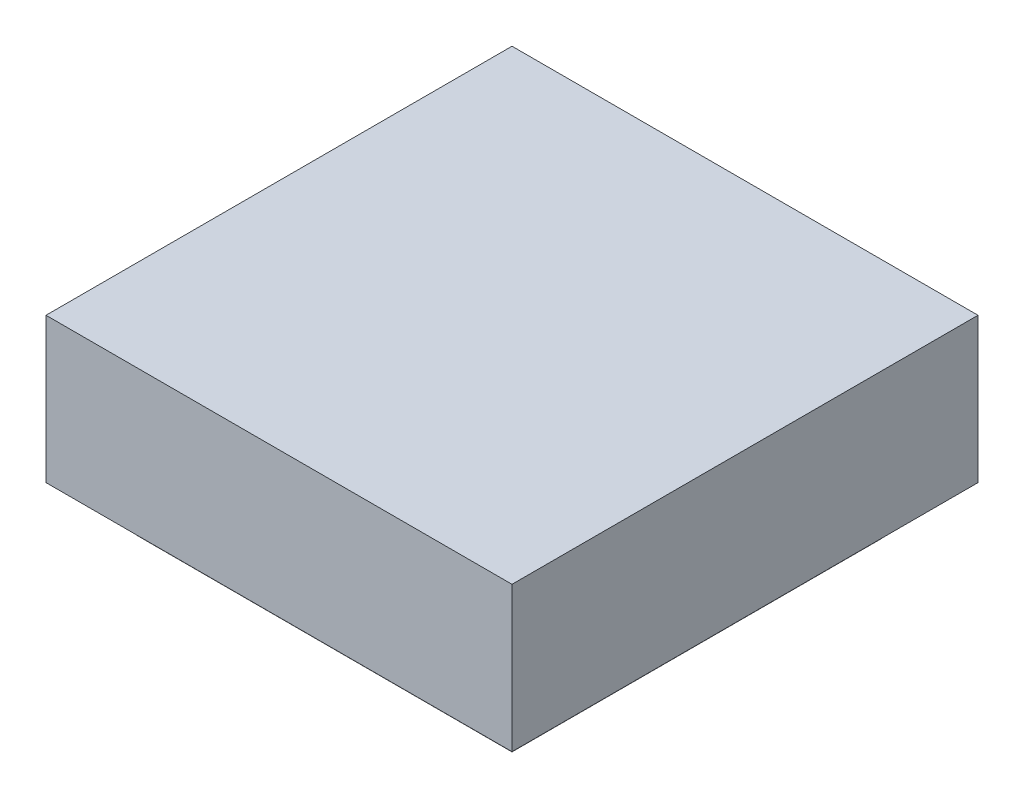
from build123d import *

# Parameters (mm, degrees)
SALIENTE_EXTRUIR1_DEPTH = 32
CORTAR_EXTRUIR2_DEPTH   = 33
SALIENTE_EXTRUIR2_DEPTH = 0.01
SALIENTE_EXTRUIR3_DEPTH = 0.01
SALIENTE_EXTRUIR5_DEPTH = 0.01
SALIENTE_EXTRUIR6_DEPTH = 0.01


with BuildPart() as part:
    # Croquis1 → Saliente-Extruir1 (new body)
    with BuildSketch(Plane.XY):
        Polygon((-23.483096056, 8.186360271), (-55.483096056, 8.189793686), (-55.483096056, 18.141275036), (-23.483096056, 18.141275036), align=None)
        Polygon((-23.483096056, 8.186360271), (-35.959662641, -4.290206314), (-43.003096056, -4.290206314), (-55.483096056, 8.189793686), align=None)
    extrude(amount=SALIENTE_EXTRUIR1_DEPTH)

    # Croquis2 → Cortar-Extruir2 (cut)
    with BuildSketch(Plane(origin=(-23.483096056, 0, 0), x_dir=(0, 0, -1), z_dir=(1, 0, 0))):
        Polygon((-12.476566586, -4.290206314), (0, -4.290206314), (0, 8.186360271), align=None)
        Polygon((-32, -4.290206314), (-32, 8.186360271), (-19.523433414, -4.290206314), align=None)
    extrude(amount=-CORTAR_EXTRUIR2_DEPTH, mode=Mode.SUBTRACT)

    # Croquis3 → Saliente-Extruir2 (add)
    with BuildSketch(Plane(origin=(0, 4.093180136, 4.093180136), x_dir=(-1, 0, 0), z_dir=(0, -0.707106781, -0.707106781))):
        with BuildLine():
            Line((28.08600417, 2.901010434), (50.876754527, 2.901010434))
            ThreePointArc((50.876754527, 2.901010434), (39.481379348, -8.494364744), (28.08600417, 2.901010434))
        make_face()
    extrude(amount=SALIENTE_EXTRUIR2_DEPTH)

    # Croquis4 → Saliente-Extruir3 (add)
    with BuildSketch(Plane(origin=(-15.834728163, 15.834728163, 0), x_dir=(-0.707106781, -0.707106781, 0), z_dir=(0.707106781, -0.707106781, 0))):
        with BuildLine():
            Line((13.640847296, -27.43326467), (13.640847296, -4.56673533))
            ThreePointArc((13.640847296, -4.56673533), (25.074111966, -16), (13.640847296, -27.43326467))
        make_face()
    extrude(amount=SALIENTE_EXTRUIR3_DEPTH)

    # Croquis5 → Saliente-Extruir5 (add)
    with BuildSketch(Plane(origin=(0, -11.906819864, 11.906819864), x_dir=(1, 0, 0), z_dir=(0, -0.707106781, 0.707106781))):
        with BuildLine():
            Line((-27.929927847, 25.798759553), (-39.481379348, 25.798759553))
            Line((-39.481379348, 25.798759553), (-51.03283085, 25.798759553))
            ThreePointArc((-51.03283085, 25.798759553), (-39.481379348, 14.247308052), (-27.929927847, 25.798759553))
        make_face()
    extrude(amount=SALIENTE_EXTRUIR5_DEPTH)

    # Croquis6 → Saliente-Extruir6 (add)
    with BuildSketch(Plane(origin=(-23.646651185, -23.646651185, 0), x_dir=(-0.707106781, 0.707106781, 0), z_dir=(-0.707106781, -0.707106781, 0))):
        with BuildLine():
            Line((42.153256878, -4.590405514), (42.153256878, -27.409594486))
            ThreePointArc((42.153256878, -27.409594486), (30.743662392, -16), (42.153256878, -4.590405514))
        make_face()
    extrude(amount=SALIENTE_EXTRUIR6_DEPTH)


solid = part.part
